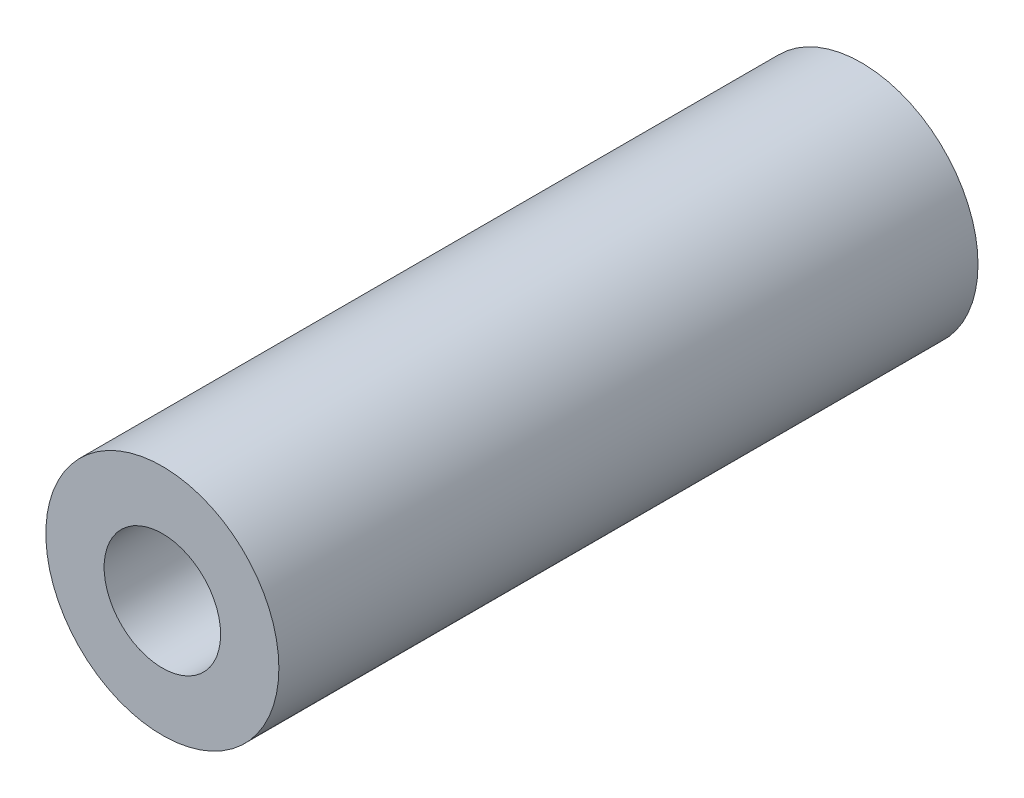
from build123d import *

# Parameters (mm, degrees)
SKETCH1_R           = 5
SKETCH1_R_2         = 2.5
BOSS_EXTRUDE1_DEPTH = 30


with BuildPart() as part:
    # Sketch1 → Boss-Extrude1 (new body)
    with BuildSketch(Plane.XY):
        Circle(SKETCH1_R)
        Circle(SKETCH1_R_2, mode=Mode.SUBTRACT)
    extrude(amount=BOSS_EXTRUDE1_DEPTH)


solid = part.part
